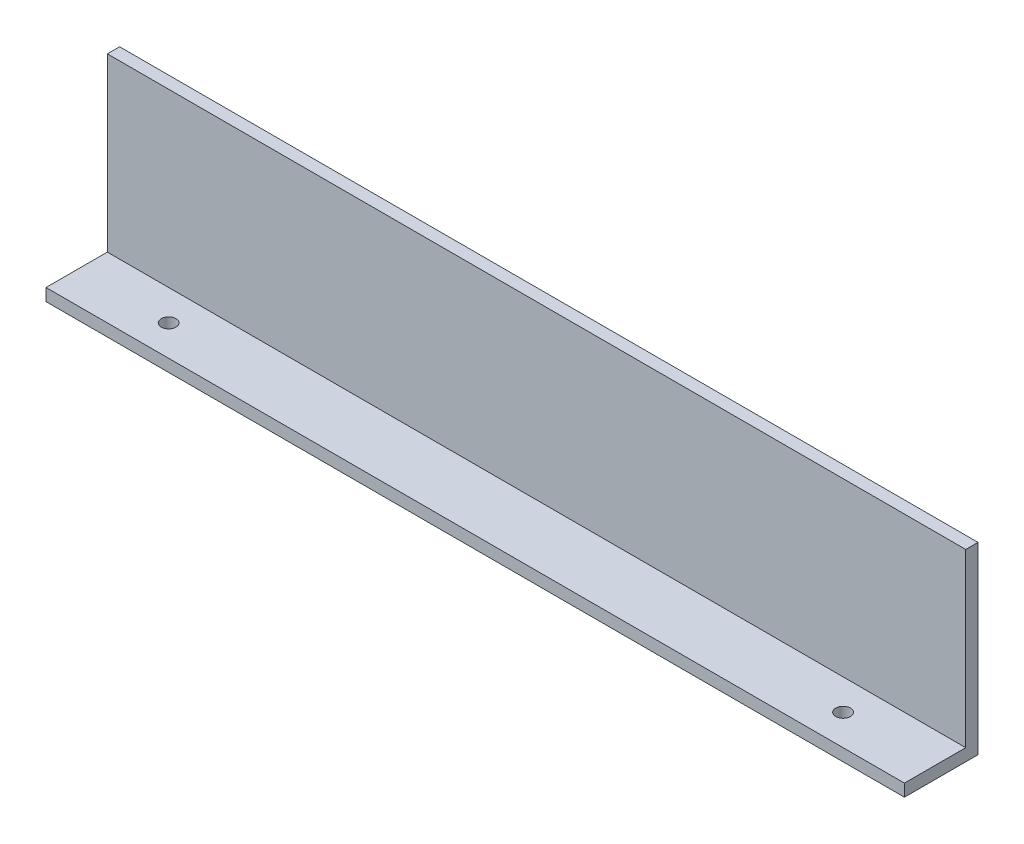
from build123d import *

# Parameters (mm, degrees)
SZKIC1_W                    = 700
SZKIC1_H                    = 150
DODANIE_WYCI_GNI_CIE1_DEPTH = 10
SZKIC2_W                    = 700
SZKIC2_H                    = 10
DODANIE_WYCI_GNI_CIE2_DEPTH = 50
OTW_R_POD_RUB_M101_D        = 12
SZYK_LINIOWY2_COUNT         = 2
SZYK_LINIOWY2_PITCH         = 550


with BuildPart() as part:
    # Szkic1 → Dodanie-wyciągnięcie1 (new body)
    with BuildSketch(Plane.XY):
        Rectangle(SZKIC1_W, SZKIC1_H)
    extrude(amount=DODANIE_WYCI_GNI_CIE1_DEPTH)

    # Szkic2 → Dodanie-wyciągnięcie2 (add)
    with BuildSketch(Plane.XY.offset(10)):
        with Locations((0, -70)):
            Rectangle(SZKIC2_W, SZKIC2_H)
    extrude(amount=DODANIE_WYCI_GNI_CIE2_DEPTH)

    # Otwór pod śrubę M101 (through all)
    with Locations(Plane(origin=(0, -65, 0), x_dir=(1, 0, 0), z_dir=(0, 1, 0))):
        with Locations((-275, -35)):
            otw_r_pod_rub_m101 = Hole(OTW_R_POD_RUB_M101_D / 2)

    # Szyk liniowy2: Otwór pod śrubę M101 ×2
    with Locations(*[(i * SZYK_LINIOWY2_PITCH, 0, 0) for i in range(1, SZYK_LINIOWY2_COUNT)]):
        add(otw_r_pod_rub_m101, mode=Mode.SUBTRACT)


solid = part.part
